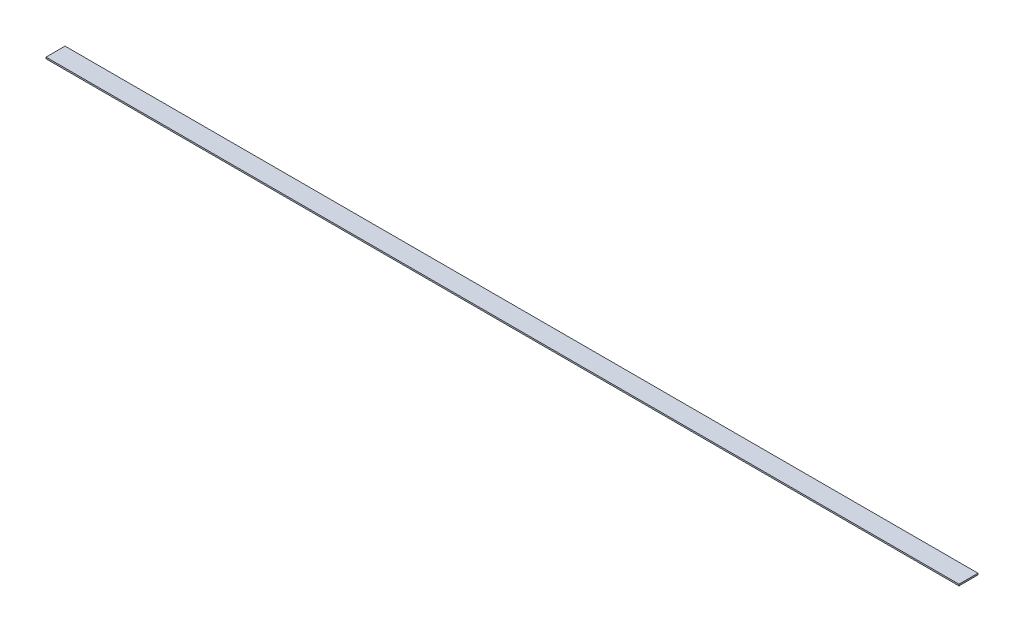
from build123d import *

# Parameters (mm, degrees)
SKETCH1_W           = 304.8
SKETCH1_H           = 6.35
BOSS_EXTRUDE1_DEPTH = 0.25


with BuildPart() as part:
    # Sketch1 → Boss-Extrude1 (new body, symmetric)
    with BuildSketch(Plane(origin=(0, 0, 0), x_dir=(1, 0, 0), z_dir=(0, 1, 0))):
        Rectangle(SKETCH1_W, SKETCH1_H)
    extrude(amount=BOSS_EXTRUDE1_DEPTH, both=True)


solid = part.part
